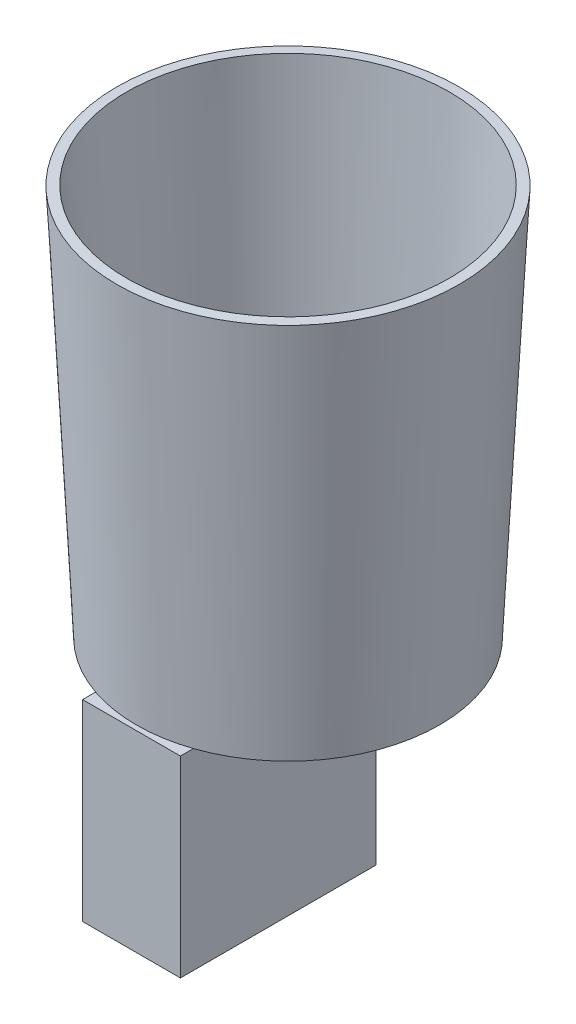
from build123d import *

# Parameters (mm, degrees)
SKETCH2_R           = 12.5
CUT_EXTRUDE1_DEPTH  = 10
SKETCH3_W           = 20
SKETCH3_H           = 40
SKETCH3_R           = 3.537482137
BOSS_EXTRUDE1_DEPTH = 39.3


with BuildPart() as part:
    # Sketch1 → Revolve1 (revolve)
    with BuildSketch(Plane.XY):
        Polygon((0, 0), (-31, 0), (-35, 80), (-33.002495322, 80.099875234), (-29.097501561, 2), (0, 2), align=None)
    revolve(axis=Axis((0, 0, 0), (0, 1, 0)))

    # Sketch2 → Cut-Extrude1 (cut)
    with BuildSketch(Plane.XZ):
        with Locations((-17.550020437, 0)):
            Circle(SKETCH2_R)
    extrude(amount=-CUT_EXTRUDE1_DEPTH, mode=Mode.SUBTRACT)

    # Sketch3 → Boss-Extrude1 (add)
    with BuildSketch(Plane.XZ):
        with Locations((0, 12)):
            Rectangle(SKETCH3_W, SKETCH3_H)
        Circle(SKETCH3_R, mode=Mode.SUBTRACT)
    extrude(amount=BOSS_EXTRUDE1_DEPTH)


solid = part.part
